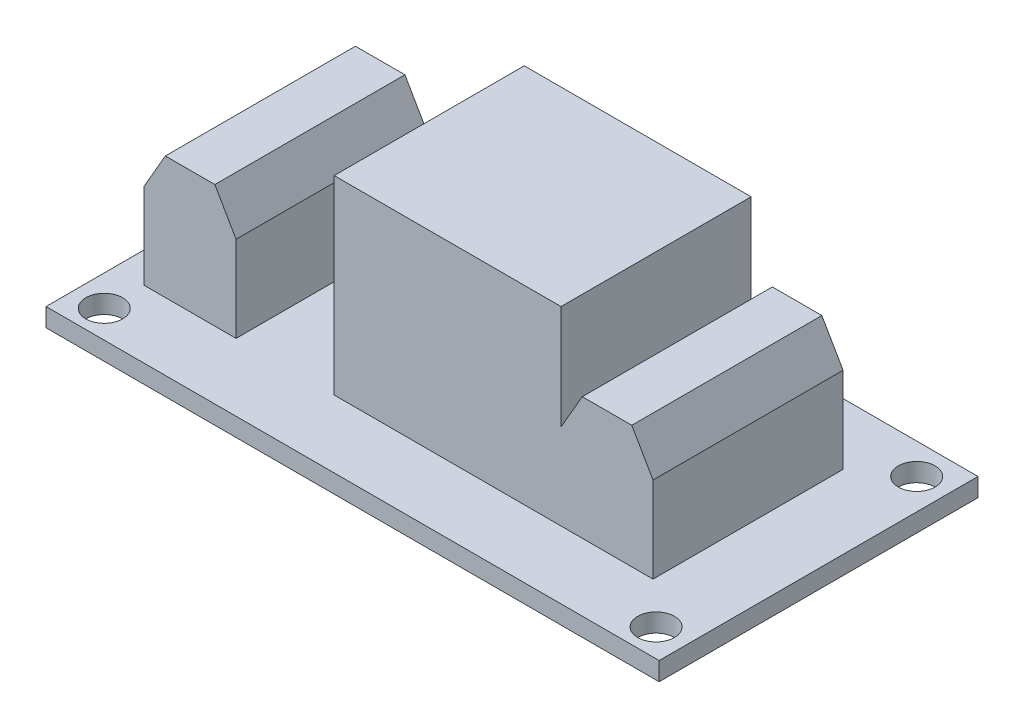
from build123d import *

# Parameters (mm, degrees)
CROQUIS1_W              = 50
CROQUIS1_H              = 26
SALIENTE_EXTRUIR1_DEPTH = 1.5
CROQUIS2_W              = 7.5
CROQUIS2_H              = 15.5
SALIENTE_EXTRUIR2_DEPTH = 10
CHAFL_N1_SIZE           = 3
CHAFL_N1_SIZE2          = 1.732050808
CHAFL_N1_PART_2_SIZE    = 3
CHAFL_N1_PART_2_SIZE2   = 1.732050808
CHAFL_N1_PART_3_SIZE    = 3
CHAFL_N1_PART_3_SIZE2   = 1.732050808
CHAFL_N1_PART_4_SIZE    = 3
CHAFL_N1_PART_4_SIZE2   = 1.732050808
CROQUIS3_W              = 18.5
CROQUIS3_H              = 15.5
SALIENTE_EXTRUIR3_DEPTH = 15.5
CROQUIS4_W              = 30
CROQUIS4_H              = 15
SALIENTE_EXTRUIR4_DEPTH = 2
CROQUIS5_R              = 1.5
CORTAR_EXTRUIR1_DEPTH   = 2


with BuildPart() as part:
    # Croquis1 → Saliente-Extruir1 (new body)
    with BuildSketch(Plane(origin=(0, 0, 0), x_dir=(1, 0, 0), z_dir=(0, 1, 0))):
        Rectangle(CROQUIS1_W, CROQUIS1_H)
    extrude(amount=SALIENTE_EXTRUIR1_DEPTH)

    # Croquis2 → Saliente-Extruir2 (add)
    with BuildSketch(Plane(origin=(0, 1.5, 0), x_dir=(1, 0, 0), z_dir=(0, 1, 0))):
        with Locations((15.25, 0.25)):
            Rectangle(CROQUIS2_W, CROQUIS2_H)
        with Locations((-18.75, 0.25)):
            Rectangle(CROQUIS2_W, CROQUIS2_H)
    extrude(amount=SALIENTE_EXTRUIR2_DEPTH)

    # Chaflán1
    chafl_n1_edges = [part.edges().sort_by_distance(p)[0] for p in [
        (19, 11.5, -0.25),
    ]]
    chafl_n1_side = [part.faces().sort_by_distance(p)[0] for p in [
        (19, 6.5, -0.25),
    ]]
    chamfer(chafl_n1_edges, length=CHAFL_N1_SIZE, length2=CHAFL_N1_SIZE2, reference=chafl_n1_side[0])

    # Chaflán1 part 2
    chafl_n1_part_2_edges = [part.edges().sort_by_distance(p)[0] for p in [
        (11.5, 11.5, -0.25),
    ]]
    chafl_n1_part_2_side = [part.faces().sort_by_distance(p)[0] for p in [
        (11.5, 6.5, -0.25),
    ]]
    chamfer(chafl_n1_part_2_edges, length=CHAFL_N1_PART_2_SIZE, length2=CHAFL_N1_PART_2_SIZE2, reference=chafl_n1_part_2_side[0])

    # Chaflán1 part 3
    chafl_n1_part_3_edges = [part.edges().sort_by_distance(p)[0] for p in [
        (-15, 11.5, -0.25),
    ]]
    chafl_n1_part_3_side = [part.faces().sort_by_distance(p)[0] for p in [
        (-15, 6.5, -0.25),
    ]]
    chamfer(chafl_n1_part_3_edges, length=CHAFL_N1_PART_3_SIZE, length2=CHAFL_N1_PART_3_SIZE2, reference=chafl_n1_part_3_side[0])

    # Chaflán1 part 4
    chafl_n1_part_4_edges = [part.edges().sort_by_distance(p)[0] for p in [
        (-22.5, 11.5, -0.25),
    ]]
    chafl_n1_part_4_side = [part.faces().sort_by_distance(p)[0] for p in [
        (-22.5, 6.5, -0.25),
    ]]
    chamfer(chafl_n1_part_4_edges, length=CHAFL_N1_PART_4_SIZE, length2=CHAFL_N1_PART_4_SIZE2, reference=chafl_n1_part_4_side[0])

    # Croquis3 → Saliente-Extruir3 (add)
    with BuildSketch(Plane(origin=(0, 1.5, 0), x_dir=(1, 0, 0), z_dir=(0, 1, 0))):
        with Locations((2.25, 0.25)):
            Rectangle(CROQUIS3_W, CROQUIS3_H)
    extrude(amount=SALIENTE_EXTRUIR3_DEPTH)

    # Croquis4 → Saliente-Extruir4 (add)
    with BuildSketch(Plane.XZ):
        Rectangle(CROQUIS4_W, CROQUIS4_H)
    extrude(amount=SALIENTE_EXTRUIR4_DEPTH)

    # Croquis5 → Cortar-Extruir1 (cut)
    with BuildSketch(Plane.XZ):
        with Locations((-22.5, 10.75)):
            Circle(CROQUIS5_R)
        with Locations((22.5, 10.75)):
            Circle(CROQUIS5_R)
        with Locations((22.5, -10.5)):
            Circle(CROQUIS5_R)
        with Locations((-22.5, -10.5)):
            Circle(CROQUIS5_R)
    extrude(amount=-CORTAR_EXTRUIR1_DEPTH, mode=Mode.SUBTRACT)


solid = part.part
